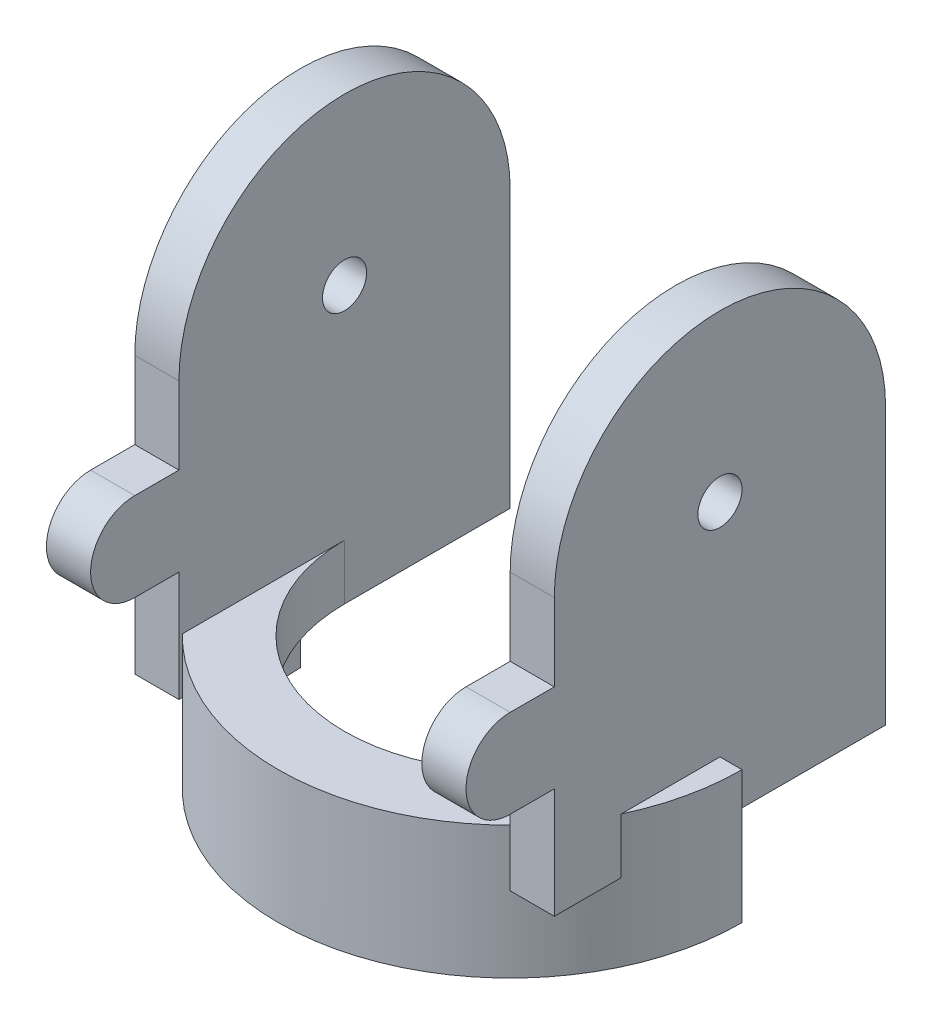
from build123d import *

# Parameters (mm, degrees)
SKETCH_1_R          = 38
SKETCH_1_R_2        = 30
EXTRUDE_1_DEPTH     = 10
SKETCH_2_W          = 8
SKETCH_2_H          = 60
EXTRUDE_2_DEPTH     = 80
SKETCH_3_R          = 4
CUT_EXTRUDE_1_DEPTH = 80
SKETCH_4_W          = 60
SKETCH_4_H          = 40.678120155
CUT_EXTRUDE_2_DEPTH = 81
EXTRUDE_3_DEPTH     = 24
SKETCH_7_W          = 8
SKETCH_7_H          = 16
EXTRUDE_5_DEPTH     = 16
CUT_EXTRUDE_3_DEPTH = 81


with BuildPart() as part:
    # 草图1 → 凸台-拉伸1 (new body)
    with BuildSketch(Plane(origin=(0, 0, 0), x_dir=(1, 0, 0), z_dir=(0, 1, 0))):
        Circle(SKETCH_1_R)
        Circle(SKETCH_1_R_2, mode=Mode.SUBTRACT)
    extrude(amount=EXTRUDE_1_DEPTH)

    # 草图2 → 凸台-拉伸2 (add)
    with BuildSketch(Plane.XZ):
        with Locations((-34, 0)):
            Rectangle(SKETCH_2_W, SKETCH_2_H)
        with Locations((34, 0)):
            Rectangle(SKETCH_2_W, SKETCH_2_H)
    extrude(amount=-EXTRUDE_2_DEPTH)

    # 草图3 → 切除-拉伸1 (cut)
    with BuildSketch(Plane(origin=(38, 0, 0), x_dir=(0, 0, -1), z_dir=(1, 0, 0))):
        with Locations((0, 50)):
            Circle(SKETCH_3_R)
        with BuildLine():
            Line((-30, 50), (-30, 88))
            Line((-30, 88), (30, 88))
            Line((30, 88), (30, 50))
            ThreePointArc((30, 50), (0, 80), (-30, 50))
        make_face()
    extrude(amount=-CUT_EXTRUDE_1_DEPTH, mode=Mode.SUBTRACT)

    # 草图4 → 切除-拉伸2 (cut, through all)
    with BuildSketch(Plane.XZ):
        with Locations((0, -20.339060078)):
            Rectangle(SKETCH_4_W, SKETCH_4_H)
    extrude(amount=-CUT_EXTRUDE_2_DEPTH, mode=Mode.SUBTRACT)

    # 草图5 → 凸台-拉伸3 (add)
    with BuildSketch(Plane(origin=(0, 10, 0), x_dir=(1, 0, 0), z_dir=(0, 1, 0))):
        with BuildLine():
            Line((42, 0), (38, 0))
            ThreePointArc((38, 0), (0, -38), (-38, 0))
            Line((-38, 0), (-42, 0))
            ThreePointArc((-42, 0), (0, -42), (42, 0))
        make_face()
    extrude(amount=-EXTRUDE_3_DEPTH)

    # 草图7 → 凸台-拉伸5 (add)
    with BuildSketch(Plane.XY.offset(30)):
        with Locations((-34, 28)):
            Rectangle(SKETCH_7_W, SKETCH_7_H)
        with Locations((34, 28)):
            Rectangle(SKETCH_7_W, SKETCH_7_H)
    extrude(amount=EXTRUDE_5_DEPTH)

    # 草图8 → 切除-拉伸3 (cut, through all)
    with BuildSketch(Plane(origin=(38, 0, 0), x_dir=(0, 0, -1), z_dir=(1, 0, 0))):
        with BuildLine():
            Line((-38, 36), (-49.79015057, 36))
            Line((-49.79015057, 36), (-49.79015057, 20))
            Line((-49.79015057, 20), (-38, 20))
            ThreePointArc((-38, 20), (-46, 28), (-38, 36))
        make_face()
    extrude(amount=-CUT_EXTRUDE_3_DEPTH, mode=Mode.SUBTRACT)


solid = part.part
